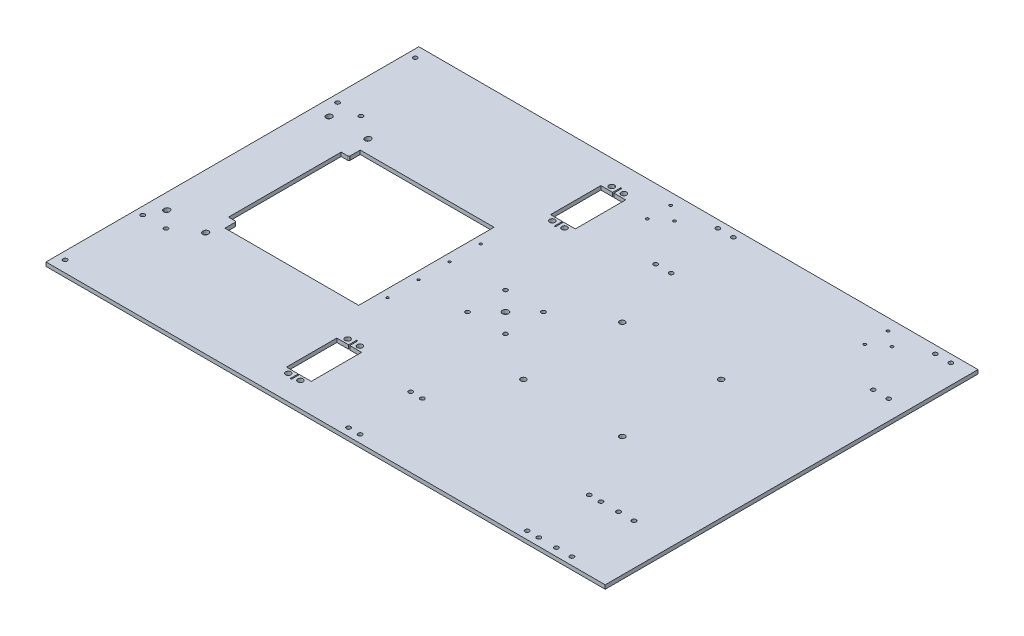
from build123d import *

# Parameters (mm, degrees)
SKETCH1_W           = 457.2
SKETCH1_H           = 304.8
BOSS_EXTRUDE1_DEPTH = 3.175
CUT_EXTRUDE1_DEPTH  = 4.175
CUT_EXTRUDE2_REACH  = 5.175
SKETCH5_R           = 1.700000029
CUT_EXTRUDE3_DEPTH  = 4.175
SKETCH7_R           = 2.200000045
CUT_EXTRUDE5_DEPTH  = 4.175
SKETCH8_R           = 1.000000032
CUT_EXTRUDE6_DEPTH  = 4.175
SKETCH12_R          = 1.700000029
CUT_EXTRUDE7_DEPTH  = 4.175
SKETCH13_R          = 1.700000029
SKETCH13_R_2        = 1.127000032
CUT_EXTRUDE8_DEPTH  = 4.175
SKETCH14_R          = 2.200000045
SKETCH14_R_2        = 1.700000029
SKETCH14_R_3        = 2.499999953
CUT_EXTRUDE9_DEPTH  = 4.175


with BuildPart() as part:
    # Sketch1 → Boss-Extrude1 (new body)
    with BuildSketch(Plane(origin=(0, 0, 0), x_dir=(1, 0, 0), z_dir=(0, 1, 0))):
        Rectangle(SKETCH1_W, SKETCH1_H)
    extrude(amount=BOSS_EXTRUDE1_DEPTH)

    # Sketch2 → Cut-Extrude1 (cut, through all)
    with BuildSketch(Plane(origin=(0, 3.175, 0), x_dir=(1, 0, 0), z_dir=(0, 1, 0))):
        with BuildLine():
            Line((-218.100000045, 66.04), (-218.100000045, 66.675))
            ThreePointArc((-218.100000045, 66.675), (-215.9, 68.875000045), (-213.699999955, 66.675))
            Line((-213.699999955, 66.675), (-213.699999955, 66.04))
            ThreePointArc((-213.699999955, 66.04), (-215.9, 63.839999955), (-218.100000045, 66.04))
        make_face()
        with BuildLine():
            Line((-186.350000045, 66.04), (-186.350000045, 66.675))
            ThreePointArc((-186.350000045, 66.675), (-184.15, 68.875000045), (-181.949999955, 66.675))
            Line((-181.949999955, 66.675), (-181.949999955, 66.04))
            ThreePointArc((-181.949999955, 66.04), (-184.15, 63.839999955), (-186.350000045, 66.04))
        make_face()
        with BuildLine():
            Line((-213.699999955, -66.04), (-213.699999955, -66.675))
            ThreePointArc((-213.699999955, -66.675), (-215.9, -68.875000045), (-218.100000045, -66.675))
            Line((-218.100000045, -66.675), (-218.100000045, -66.04))
            ThreePointArc((-218.100000045, -66.04), (-215.9, -63.839999955), (-213.699999955, -66.04))
        make_face()
        with BuildLine():
            Line((-181.949999955, -66.04), (-181.949999955, -66.675))
            ThreePointArc((-181.949999955, -66.675), (-184.15, -68.875000045), (-186.350000045, -66.675))
            Line((-186.350000045, -66.675), (-186.350000045, -66.04))
            ThreePointArc((-186.350000045, -66.04), (-184.15, -63.839999955), (-181.949999955, -66.04))
        make_face()
    extrude(amount=-CUT_EXTRUDE1_DEPTH, mode=Mode.SUBTRACT)

    # Sketch4 → Cut-Extrude2 (cut, up to next)
    with BuildSketch(Plane(origin=(0, 3.175, 0), x_dir=(1, 0, 0), z_dir=(0, 1, 0)), mode=Mode.PRIVATE) as cut_extrude2_sk1:
        with BuildLine():
            Line((-185.7375, 46.0375), (-185.7375, -46.0375))
            Line((-185.7375, -46.0375), (-180.34, -46.0375))
            ThreePointArc((-180.34, -46.0375), (-179.666480791, -46.316480791), (-179.3875, -46.99))
            Line((-179.3875, -46.99), (-179.3875, -55.3085))
            Line((-179.3875, -55.3085), (-70.0405, -55.3085))
            Line((-70.0405, -55.3085), (-70.0405, 55.3085))
            Line((-70.0405, 55.3085), (-179.3875, 55.3085))
            Line((-179.3875, 55.3085), (-179.3875, 46.99))
            ThreePointArc((-179.3875, 46.99), (-179.666480791, 46.316480791), (-180.34, 46.0375))
            Line((-180.34, 46.0375), (-185.7375, 46.0375))
        make_face()
    cut_extrude2_tool1 = extrude(cut_extrude2_sk1.sketch, amount=-CUT_EXTRUDE2_REACH, mode=Mode.PRIVATE) & part.part
    add(cut_extrude2_tool1.solids().sort_by_distance((-127.382939, 3.175, 0))[0], mode=Mode.SUBTRACT)

    # Sketch5 → Cut-Extrude3 (cut, through all)
    with BuildSketch(Plane(origin=(0, 3.175, 0), x_dir=(1, 0, 0), z_dir=(0, 1, 0))):
        with Locations((-203.2, 79.629)):
            Circle(SKETCH5_R)
        with Locations((-222.25, 143.129)):
            Circle(SKETCH5_R)
        with Locations((-222.25, 79.629)):
            Circle(SKETCH5_R)
        with Locations((-203.2, -79.629)):
            Circle(SKETCH5_R)
        with Locations((-222.25, -79.629)):
            Circle(SKETCH5_R)
        with Locations((-222.25, -143.129)):
            Circle(SKETCH5_R)
    extrude(amount=-CUT_EXTRUDE3_DEPTH, mode=Mode.SUBTRACT)

    # Sketch7 → Cut-Extrude5 (cut, through all)
    with BuildSketch(Plane(origin=(0, 3.175, 0), x_dir=(1, 0, 0), z_dir=(0, 1, 0))):
        with Locations((-50.720000033, -132.250000041)):
            Circle(SKETCH7_R)
        with Locations((-40.719999967, -132.250000041)):
            Circle(SKETCH7_R)
        with Locations((-50.720000033, -83.649999959)):
            Circle(SKETCH7_R)
        with Locations((-40.719999967, -83.649999959)):
            Circle(SKETCH7_R)
        Polygon((-55.846999939, -87.373000006), (-46.22, -87.373000006), (-46.22, -80.769000006), (-45.22, -80.769000006), (-45.22, -87.373000006), (-35.593000061, -87.373000006), (-35.593000061, -128.526999994), (-45.22, -128.526999994), (-45.22, -135.130999994), (-46.22, -135.130999994), (-46.22, -128.526999994), (-55.846999939, -128.526999994), align=None)
    cut_extrude5 = extrude(amount=-CUT_EXTRUDE5_DEPTH, mode=Mode.SUBTRACT)

    # Mirror1: Cut-Extrude5 across plane
    add(cut_extrude5.mirror(Plane.XY), mode=Mode.SUBTRACT)

    # Sketch8 → Cut-Extrude6 (cut, through all)
    with BuildSketch(Plane(origin=(0, 3.175, 0), x_dir=(1, 0, 0), z_dir=(0, 1, 0))):
        with Locations((-63.6905, -38.1)):
            Circle(SKETCH8_R)
        with Locations((-63.6905, -12.7)):
            Circle(SKETCH8_R)
        with Locations((-63.6905, 12.7)):
            Circle(SKETCH8_R)
        with Locations((-63.6905, 38.1)):
            Circle(SKETCH8_R)
    extrude(amount=-CUT_EXTRUDE6_DEPTH, mode=Mode.SUBTRACT)

    # Sketch12 → Cut-Extrude7 (cut, through all)
    with BuildSketch(Plane(origin=(0, 3.175, 0), x_dir=(1, 0, 0), z_dir=(0, 1, 0))):
        with Locations((195.024, -95.25)):
            Circle(SKETCH12_R)
        with Locations((182.324, -95.25)):
            Circle(SKETCH12_R)
        with Locations((195.024, -146.05)):
            Circle(SKETCH12_R)
        with Locations((182.324, -146.05)):
            Circle(SKETCH12_R)
        with Locations((167.9575, -95.25)):
            Circle(SKETCH12_R)
        with Locations((158.4325, -95.25)):
            Circle(SKETCH12_R)
        with Locations((167.9575, -146.05)):
            Circle(SKETCH12_R)
        with Locations((158.4325, -146.05)):
            Circle(SKETCH12_R)
        with Locations((21.9075, -146.05)):
            Circle(SKETCH12_R)
        with Locations((12.3825, -146.05)):
            Circle(SKETCH12_R)
        with Locations((12.3825, -95.25)):
            Circle(SKETCH12_R)
        with Locations((21.9075, -95.25)):
            Circle(SKETCH12_R)
    extrude(amount=-CUT_EXTRUDE7_DEPTH, mode=Mode.SUBTRACT)

    # Sketch13 → Cut-Extrude8 (cut, through all)
    with BuildSketch(Plane(origin=(0, 3.175, 0), x_dir=(1, 0, 0), z_dir=(0, 1, 0))):
        with Locations((212.725, 95.25)):
            Circle(SKETCH13_R)
        with Locations((212.725, 146.05)):
            Circle(SKETCH13_R)
        with Locations((200.025, 95.25)):
            Circle(SKETCH13_R)
        with Locations((200.025, 146.05)):
            Circle(SKETCH13_R)
        with Locations((177.213, 133.477000026)):
            Circle(SKETCH13_R_2)
        with Locations((164.513, 143.002000026)):
            Circle(SKETCH13_R_2)
        with Locations((164.513, 123.952000026)):
            Circle(SKETCH13_R_2)
        with Locations((34.925, 95.25)):
            Circle(SKETCH13_R)
        with Locations((34.925, 146.05)):
            Circle(SKETCH13_R)
        with Locations((22.225, 95.25)):
            Circle(SKETCH13_R)
        with Locations((22.225, 146.05)):
            Circle(SKETCH13_R)
        with Locations((-0.587, 133.477000026)):
            Circle(SKETCH13_R_2)
        with Locations((-13.287, 143.002000026)):
            Circle(SKETCH13_R_2)
        with Locations((-13.287, 123.952000026)):
            Circle(SKETCH13_R_2)
    extrude(amount=-CUT_EXTRUDE8_DEPTH, mode=Mode.SUBTRACT)

    # Sketch14 → Cut-Extrude9 (cut, through all)
    with BuildSketch(Plane(origin=(0, 3.175, 0), x_dir=(1, 0, 0), z_dir=(0, 1, 0))):
        with Locations((49.758847455, 40.411152545)):
            Circle(SKETCH14_R)
        with Locations((130.581152545, 40.411152545)):
            Circle(SKETCH14_R)
        with Locations((49.758847455, -40.411152545)):
            Circle(SKETCH14_R)
        with Locations((130.581152545, -40.411152545)):
            Circle(SKETCH14_R)
        with Locations((-20.833999988, 15.499999988)):
            Circle(SKETCH14_R_2)
        with Locations((10.165999988, 15.499999988)):
            Circle(SKETCH14_R_2)
        with Locations((-20.833999988, -15.499999988)):
            Circle(SKETCH14_R_2)
        with Locations((10.165999988, -15.499999988)):
            Circle(SKETCH14_R_2)
        with Locations((-5.334, 0)):
            Circle(SKETCH14_R_3)
    extrude(amount=-CUT_EXTRUDE9_DEPTH, mode=Mode.SUBTRACT)


solid = part.part
